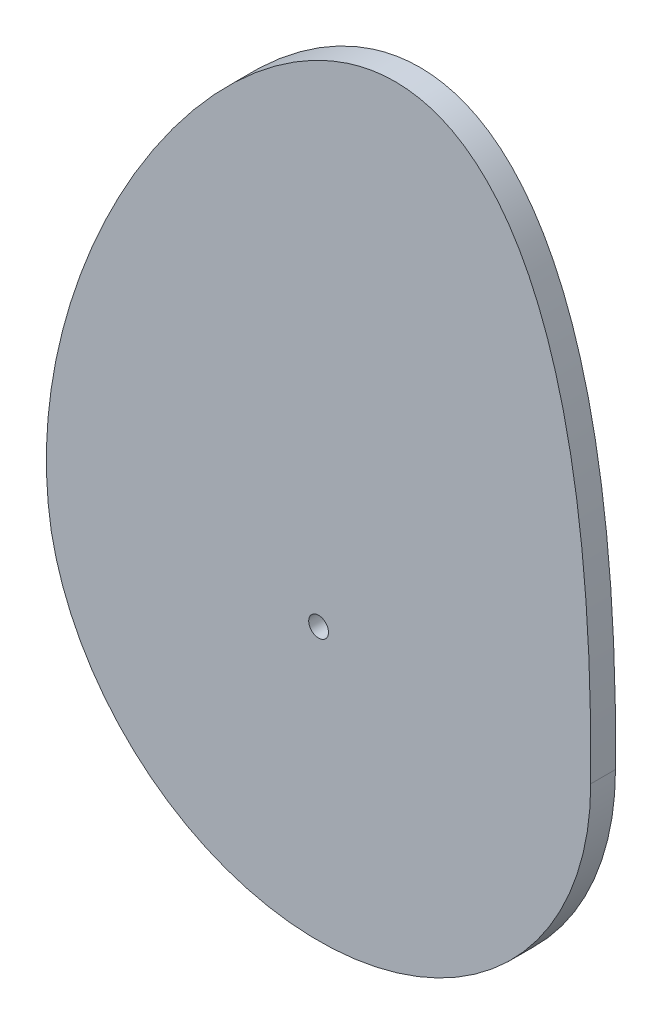
from build123d import *

# Parameters (mm, degrees)
SKETCH1_R           = 2
BOSS_EXTRUDE1_DEPTH = 5


with BuildPart() as part:
    # Sketch1 → Boss-Extrude1 (new body)
    with BuildSketch(Plane.XY):
        with BuildLine():
            ThreePointArc((-54.044325591, -10.208372612), (5.12650429, -54.760560203), (55, 0))
            add(Edge.make_bspline(
                [(55, 0), (56.761883758, 195.857792895), (-67.173590813, 66.398085784), (-54.044325591, -10.208372612)],
                knots=[0, 0, 0, 0, 1, 1, 1, 1], degree=3))
        make_face()
        Circle(SKETCH1_R, mode=Mode.SUBTRACT)
    extrude(amount=BOSS_EXTRUDE1_DEPTH)


solid = part.part
